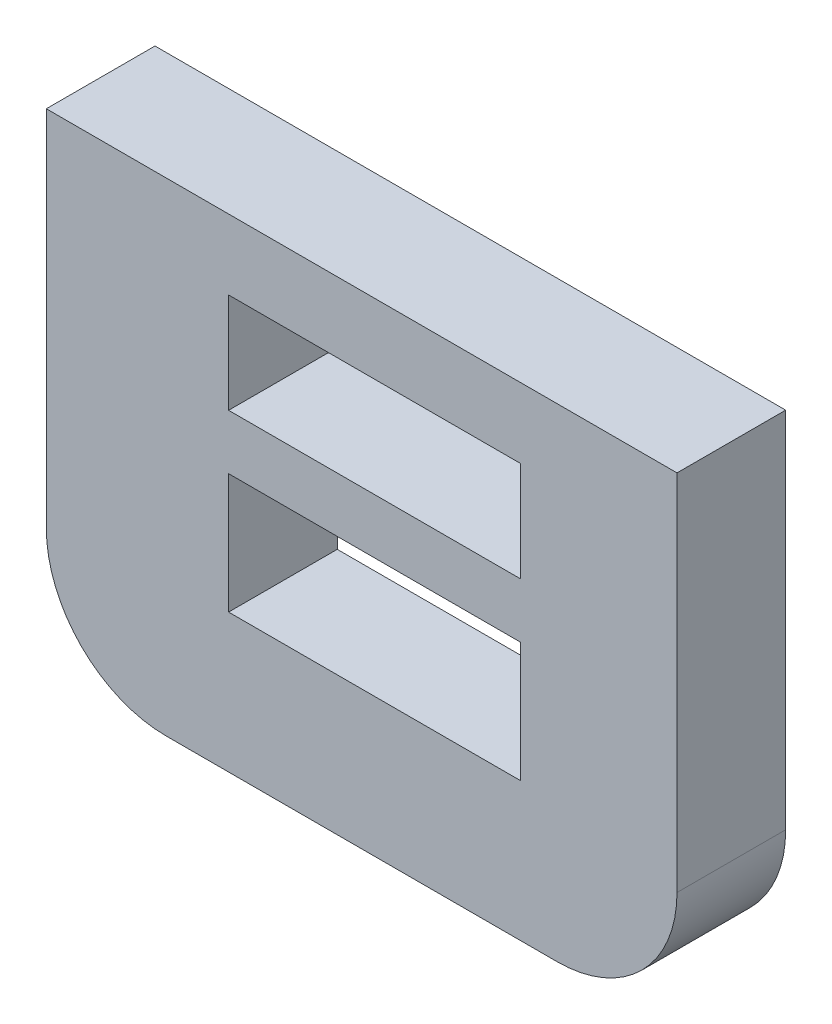
from build123d import *

# Parameters (mm, degrees)
SKETCH1_W           = 7.305190172
SKETCH1_H           = 3
SKETCH1_H_2         = 2.5
BOSS_EXTRUDE1_DEPTH = 2.719448


with BuildPart() as part:
    # Sketch1 → Boss-Extrude1 (new body)
    with BuildSketch(Plane.XY):
        with BuildLine():
            Line((-25.252187622, -417.522040931), (-35.0337538, -417.522040931))
            ThreePointArc((-35.0337538, -417.522040931), (-37.155074144, -416.643361274), (-38.0337538, -414.522040931))
            Line((-38.0337538, -414.522040931), (-38.0337538, -405.428571358))
            Line((-38.0337538, -405.428571358), (-22.252187622, -405.428571358))
            Line((-22.252187622, -405.428571358), (-22.252187622, -414.522040931))
            ThreePointArc((-22.252187622, -414.522040931), (-23.130867278, -416.643361274), (-25.252187622, -417.522040931))
        make_face()
        with Locations((-29.82012001, -412.555740742)):
            Rectangle(SKETCH1_W, SKETCH1_H, mode=Mode.SUBTRACT)
        with Locations((-29.82012001, -408.432910126)):
            Rectangle(SKETCH1_W, SKETCH1_H_2, mode=Mode.SUBTRACT)
    extrude(amount=BOSS_EXTRUDE1_DEPTH)


solid = part.part
